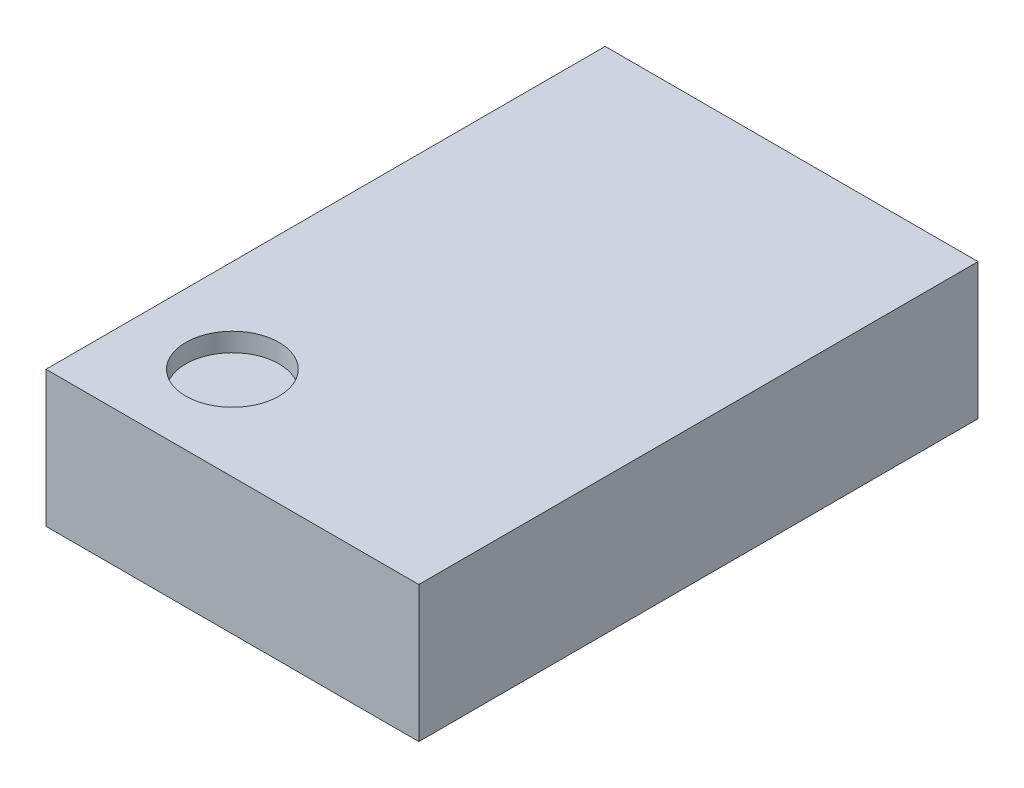
from build123d import *

# Parameters (mm, degrees)
SKETCH1_W           = 2
SKETCH1_H           = 3
BOSS_EXTRUDE1_DEPTH = 0.73
SKETCH2_R           = 0.25
CUT_EXTRUDE1_DEPTH  = 0.1


with BuildPart() as part:
    # Sketch1 → Boss-Extrude1 (new body)
    with BuildSketch(Plane(origin=(0, 0, 0), x_dir=(1, 0, 0), z_dir=(0, 1, 0))):
        Rectangle(SKETCH1_W, SKETCH1_H)
    extrude(amount=BOSS_EXTRUDE1_DEPTH)

    # Sketch2 → Cut-Extrude1 (cut)
    with BuildSketch(Plane(origin=(0, 0.73, 0), x_dir=(1, 0, 0), z_dir=(0, 1, 0))):
        with Locations((-0.5, -1)):
            Circle(SKETCH2_R)
    extrude(amount=-CUT_EXTRUDE1_DEPTH, mode=Mode.SUBTRACT)


solid = part.part
